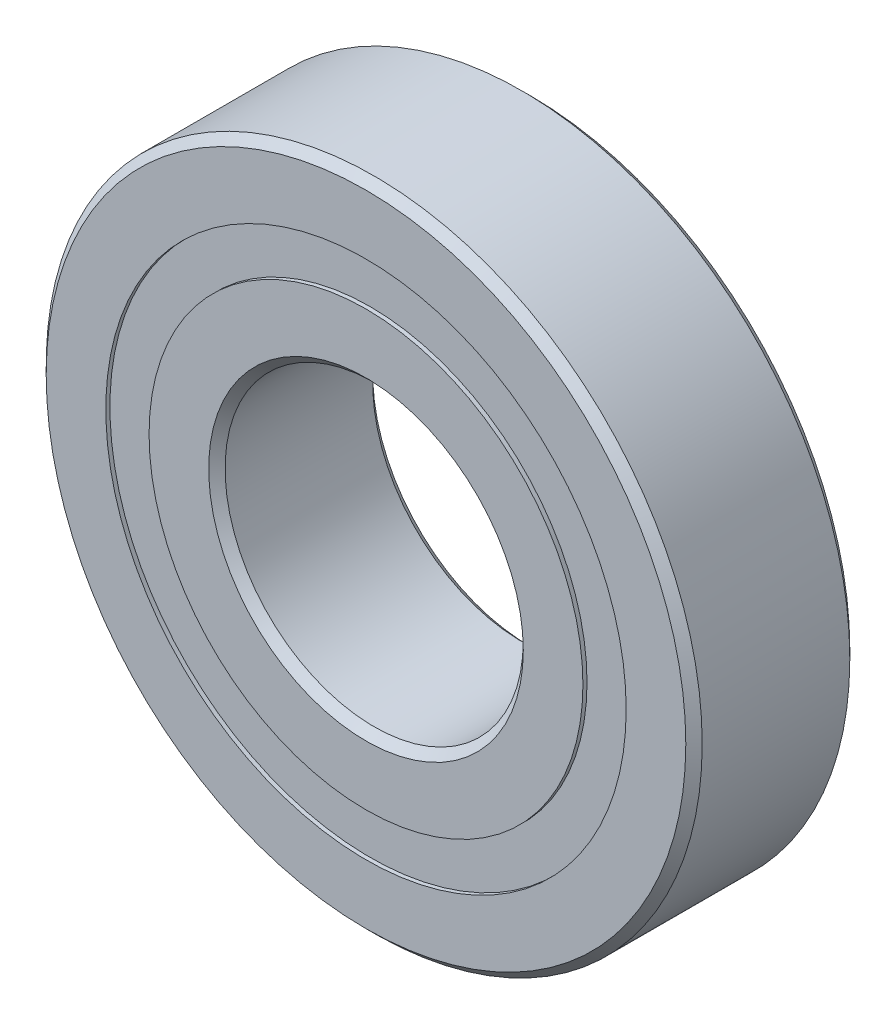
from build123d import *

# Parameters (mm, degrees)
CIRPATTERN1_COUNT = 10
SKETCH5_W         = 1.891165769
SKETCH5_H         = 2.302747252


with BuildPart() as part:
    # Sketch1 → Revolve1 (revolve)
    with BuildSketch(Plane(origin=(0, 0, 0), x_dir=(0, 0, -1), z_dir=(1, 0, 0)), mode=Mode.PRIVATE) as revolve1_sk:
        with BuildLine():
            Line((3.9290625, 17.4625), (-3.9290625, 17.4625))
            Line((-3.9290625, 17.4625), (-4.365625, 17.0259375))
            Line((-4.365625, 17.0259375), (-4.365625, 13.851373626))
            Line((-4.365625, 13.851373626), (-1.940277778, 13.851373626))
            ThreePointArc((-1.940277778, 13.851373626), (0, 14.956177981), (1.940277778, 13.851373626))
            Line((1.940277778, 13.851373626), (4.365625, 13.851373626))
            Line((4.365625, 13.851373626), (4.365625, 17.0259375))
            Line((4.365625, 17.0259375), (3.9290625, 17.4625))
        make_face()
    revolve(revolve1_sk.sketch.rotate(Axis((0, 0, 4.365625), (0, 0, -1)), 90), axis=Axis((0, 0, 4.365625), (0, 0, -1)))  # turned: the seam where the file's is


with BuildPart() as body_2:
    # Sketch3 → Revolve3 (revolve)
    with BuildSketch(Plane(origin=(0, 0, 0), x_dir=(0, 0, -1), z_dir=(1, 0, 0)), mode=Mode.PRIVATE) as revolve3_sk:
        with BuildLine():
            Line((-4.365625, 11.548626374), (-1.940277778, 11.548626374))
            ThreePointArc((-1.940277778, 11.548626374), (0, 10.443822019), (1.940277778, 11.548626374))
            Line((1.940277778, 11.548626374), (4.365625, 11.548626374))
            Line((4.365625, 11.548626374), (4.365625, 8.3740625))
            Line((4.365625, 8.3740625), (3.9290625, 7.9375))
            Line((3.9290625, 7.9375), (-3.9290625, 7.9375))
            Line((-3.9290625, 7.9375), (-4.365625, 8.3740625))
            Line((-4.365625, 8.3740625), (-4.365625, 11.548626374))
        make_face()
    revolve(revolve3_sk.sketch.rotate(Axis((0, 0, 4.365625), (0, 0, -1)), 90), axis=Axis((0, 0, 4.365625), (0, 0, -1)))  # turned: the seam where the file's is


with BuildPart() as body_3:
    # Sketch4 → Revolve4 (revolve)
    with BuildSketch(Plane(origin=(0, 0, 0), x_dir=(0, 0, -1), z_dir=(1, 0, 0))):
        with BuildLine():
            Line((-2.256177981, 12.7), (2.256177981, 12.7))
            ThreePointArc((2.256177981, 12.7), (0, 14.956177981), (-2.256177981, 12.7))
        make_face()
    revolve(axis=Axis((0, 12.7, 2.256177981), (0, 0, -1)))


with BuildPart() as cirpattern1_1:
    # CirPattern1: pattern copy
    add(body_3.part.rotate(Axis((0, 0, 0), (0, 0, 1)), 1 * 360 / CIRPATTERN1_COUNT))


with BuildPart() as cirpattern1_2:
    # CirPattern1: pattern copy
    add(body_3.part.rotate(Axis((0, 0, 0), (0, 0, 1)), 2 * 360 / CIRPATTERN1_COUNT))


with BuildPart() as cirpattern1_3:
    # CirPattern1: pattern copy
    add(body_3.part.rotate(Axis((0, 0, 0), (0, 0, 1)), 3 * 360 / CIRPATTERN1_COUNT))


with BuildPart() as cirpattern1_4:
    # CirPattern1: pattern copy
    add(body_3.part.rotate(Axis((0, 0, 0), (0, 0, 1)), 4 * 360 / CIRPATTERN1_COUNT))


with BuildPart() as cirpattern1_5:
    # CirPattern1: pattern copy
    add(body_3.part.rotate(Axis((0, 0, 0), (0, 0, 1)), 5 * 360 / CIRPATTERN1_COUNT))


with BuildPart() as cirpattern1_6:
    # CirPattern1: pattern copy
    add(body_3.part.rotate(Axis((0, 0, 0), (0, 0, 1)), 6 * 360 / CIRPATTERN1_COUNT))


with BuildPart() as cirpattern1_7:
    # CirPattern1: pattern copy
    add(body_3.part.rotate(Axis((0, 0, 0), (0, 0, 1)), 7 * 360 / CIRPATTERN1_COUNT))


with BuildPart() as cirpattern1_8:
    # CirPattern1: pattern copy
    add(body_3.part.rotate(Axis((0, 0, 0), (0, 0, 1)), 8 * 360 / CIRPATTERN1_COUNT))


with BuildPart() as cirpattern1_9:
    # CirPattern1: pattern copy
    add(body_3.part.rotate(Axis((0, 0, 0), (0, 0, 1)), 9 * 360 / CIRPATTERN1_COUNT))


with BuildPart() as body_13:
    # Sketch5 → Revolve5 (revolve)
    with BuildSketch(Plane(origin=(0, 0, 0), x_dir=(0, 0, -1), z_dir=(1, 0, 0)), mode=Mode.PRIVATE) as revolve5_sk:
        with Locations((-3.201760865, 12.7)):
            Rectangle(SKETCH5_W, SKETCH5_H)
        with Locations((3.201760865, 12.7)):
            Rectangle(SKETCH5_W, SKETCH5_H)
    revolve(revolve5_sk.sketch.rotate(Axis((0, 0, 4.365625), (0, 0, -1)), 90), axis=Axis((0, 0, 4.365625), (0, 0, -1)))  # turned: the seam where the file's is


solid = Compound([part.part, body_2.part, body_3.part, cirpattern1_1.part, cirpattern1_2.part, cirpattern1_3.part, cirpattern1_4.part, cirpattern1_5.part, cirpattern1_6.part, cirpattern1_7.part, cirpattern1_8.part, cirpattern1_9.part, body_13.part])
